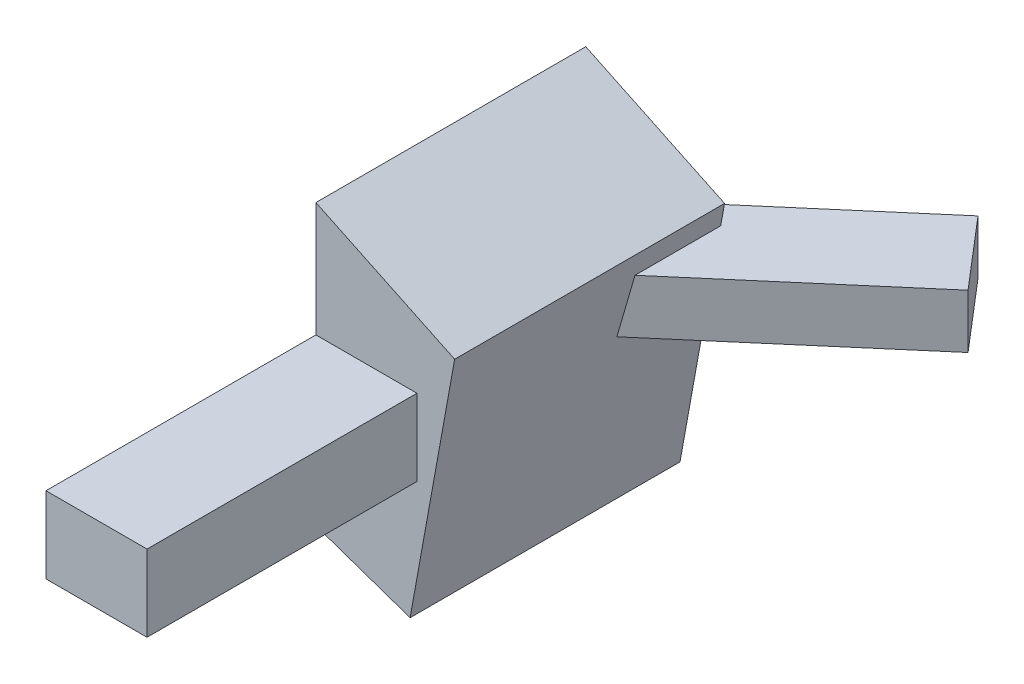
from build123d import *

# Parameters (mm, degrees)
BOSS_EXTRU_1_DEPTH = 500
ESQUISSE2_W        = 187.1782881
ESQUISSE2_H        = 141.58126374
BOSS_EXTRU_2_DEPTH = 500
ESQUISSE3_R        = 76.59677213
BOSS_EXTRU_3_DEPTH = 100
BOSS_EXTRU_4_DEPTH = 50


with BuildPart() as part:
    # Esquisse1 → Boss.-Extru.1 (new body)
    with BuildSketch(Plane.XY):
        Polygon((0, 0), (0, 518.568521206), (257.06807621, 395.669035808), (174.541368625, -60.305866535), align=None)
    extrude(amount=BOSS_EXTRU_1_DEPTH)

    # Esquisse2 → Boss.-Extru.2 (add)
    with BuildSketch(Plane.XY.offset(500)):
        with Locations((93.58914405, 235.39430549)):
            Rectangle(ESQUISSE2_W, ESQUISSE2_H)
    extrude(amount=BOSS_EXTRU_2_DEPTH)

    # Esquisse3 → Boss.-Extru.3 (add)
    with BuildSketch(Plane.ZY):
        with Locations(Location((229.683047697, 238.758360313, 0), (0, 0, 180))):  # turned: the seam where the file's is
            Circle(ESQUISSE3_R)
    extrude(amount=BOSS_EXTRU_3_DEPTH)

    # Esquisse5 → Boss.-Extru.4 (add, symmetric)
    with BuildSketch(Plane(origin=(0, 306.18493736, 0), x_dir=(1, 0, 0), z_dir=(0, 1, 0))):
        Polygon((472.369351722, 254.21152486), (582.306234848, 125.789679085), (231.997079223, -174.096188988), (122.060196097, -45.674343213), align=None)
    extrude(amount=BOSS_EXTRU_4_DEPTH, both=True)


solid = part.part
